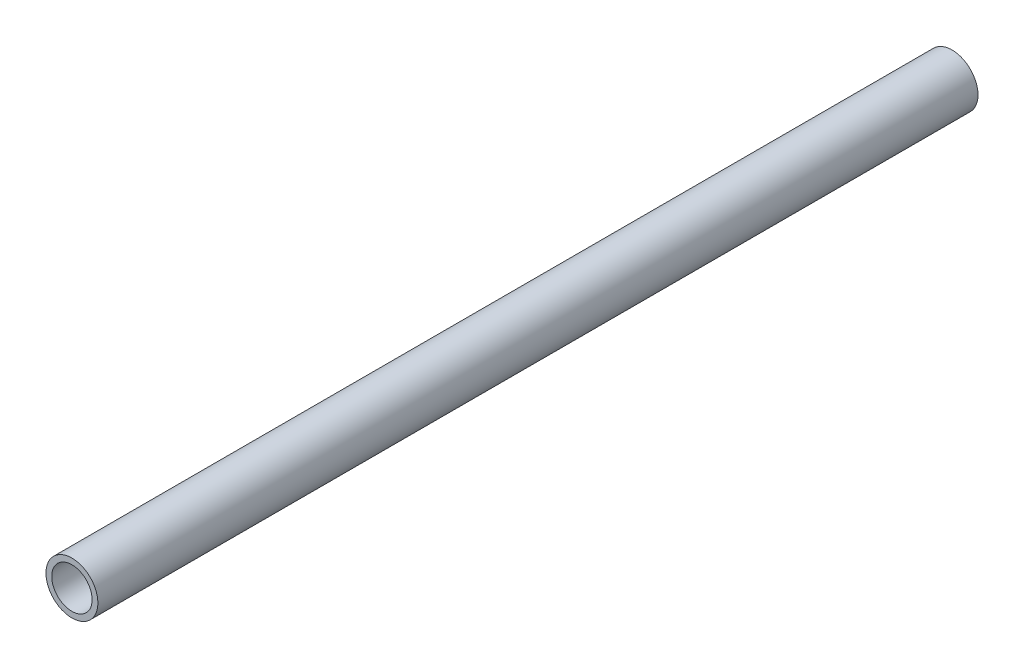
from build123d import *

# Parameters (mm, degrees)
ESQUISSE1_R            = 9
EXTRUSION1_DEPTH       = 305
TROU_TARAUD_M16X2_01_D = 14


with BuildPart() as part:
    # Esquisse1 → Extrusion1 (new body)
    with BuildSketch(Plane.XY):
        Circle(ESQUISSE1_R)
    extrude(amount=EXTRUSION1_DEPTH)

    # Trou taraudé M16x2.01 (through all)
    with Locations(Plane.XY.offset(305)):
        with Locations((0, 0)):
            Hole(TROU_TARAUD_M16X2_01_D / 2)


solid = part.part
